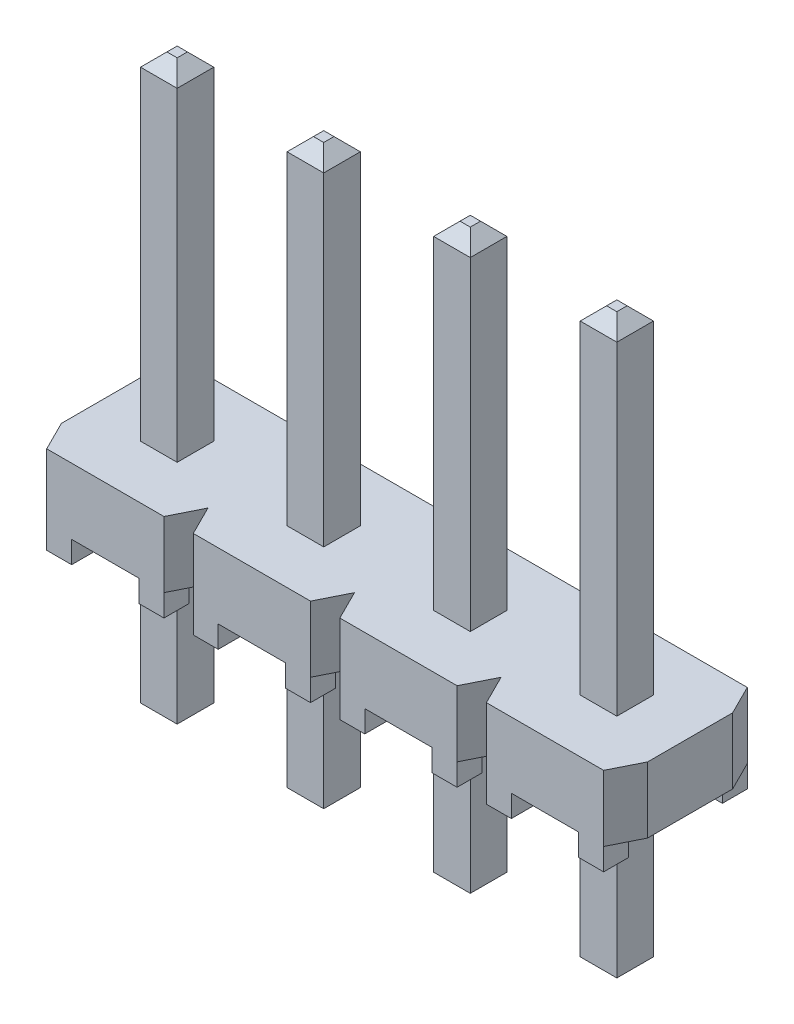
from build123d import *

# Parameters (mm, degrees)
SKETCH1_W                        = 10.16
SKETCH1_H                        = 2.4892
BASE_EXTRUDE_DEPTH               = 0.5715
SNAP_GROOVES_DEPTH               = 2.143
SKETCH4_W                        = 0.4318
SKETCH4_H                        = 0.4318
STANDOFFS_DEPTH                  = 0.381
POSITION_PATTERN_COUNT           = 4
POSITION_PATTERN_PITCH           = 2.54
SKETCH5_W                        = 0.635
SKETCH5_H                        = 10
TERMINAL_TH_DEPTH                = 0.3175
T1_TIP1_SIZE                     = 0.2286
TERMINAL_PATTERN_COUNT           = 4
TERMINAL_PATTERN_PITCH           = 2.54
T1_TIP1_OF_TERMINAL_PATTERN_SIZE = 0.2286


with BuildPart() as part:
    # Sketch1 → Base-Extrude (new body, symmetric)
    with BuildSketch(Plane(origin=(0, 0, 0), x_dir=(1, 0, 0), z_dir=(0, 1, 0))):
        Rectangle(SKETCH1_W, SKETCH1_H)
    extrude(amount=BASE_EXTRUDE_DEPTH, both=True)

    # Sketch3 → Snap Grooves (cut, through all)
    with BuildSketch(Plane(origin=(0, 0.5715, 0), x_dir=(-1, 0, 0), z_dir=(0, 1, 0))):
        Polygon((2.286, 1.2446), (2.794, 1.2446), (2.54, 0.7366), align=None)
        Polygon((2.286, -1.2446), (2.794, -1.2446), (2.54, -0.7366), align=None)
        Polygon((5.08, -0.7366), (5.334, -1.2446), (4.826, -1.2446), align=None)
        Polygon((5.08, 0.7366), (5.334, 1.2446), (4.826, 1.2446), align=None)
    snap_grooves = extrude(amount=-SNAP_GROOVES_DEPTH, mode=Mode.SUBTRACT)

    # Sketch4 → Standoffs (add)
    with BuildSketch(Plane.XZ.offset(0.5715)):
        with Locations((-4.6101, 1.0287)):
            Rectangle(SKETCH4_W, SKETCH4_H)
        with Locations((-3.0099, 1.0287)):
            Rectangle(SKETCH4_W, SKETCH4_H)
        with Locations((-3.0099, -1.0287)):
            Rectangle(SKETCH4_W, SKETCH4_H)
        with Locations((-4.6101, -1.0287)):
            Rectangle(SKETCH4_W, SKETCH4_H)
    standoffs = extrude(amount=STANDOFFS_DEPTH)

    # Position Pattern: Snap Grooves, Standoffs ×4
    with Locations(*[(i * POSITION_PATTERN_PITCH, 0, 0) for i in range(1, POSITION_PATTERN_COUNT)]):
        add(snap_grooves, mode=Mode.SUBTRACT)
        add(standoffs)

    # Sketch5 → Terminal -TH (add, symmetric)
    with BuildSketch(Plane.ZY.offset(3.81)):
        with Locations((0, 1.4135)):
            Rectangle(SKETCH5_W, SKETCH5_H)
    terminal_th = extrude(amount=TERMINAL_TH_DEPTH, both=True)

    # T1 Tip1
    t1_tip1_edges = [part.edges().sort_by_distance(p)[0] for p in [
        (-3.81, -3.5865, 0.3175),
        (-4.1275, -3.5865, 0),
        (-3.81, 6.4135, -0.3175),
        (-3.4925, -3.5865, 0),
        (-3.81, -3.5865, -0.3175),
        (-3.4925, 6.4135, 0),
        (-3.81, 6.4135, 0.3175),
        (-4.1275, 6.4135, 0),
    ]]
    chamfer(t1_tip1_edges, length=T1_TIP1_SIZE)

    # Terminal Pattern: Terminal -TH ×4
    with Locations(*[(i * TERMINAL_PATTERN_PITCH, 0, 0) for i in range(1, TERMINAL_PATTERN_COUNT)]):
        add(terminal_th)

    # T1 Tip1 of Terminal Pattern
    t1_tip1_of_terminal_pattern_edges = [part.edges().sort_by_distance(p)[0] for p in [
        (-1.27, -3.5865, 0.3175),
        (-1.5875, -3.5865, 0),
        (-1.27, 6.4135, -0.3175),
        (-0.9525, -3.5865, 0),
        (-1.27, -3.5865, -0.3175),
        (-0.9525, 6.4135, 0),
        (-1.27, 6.4135, 0.3175),
        (-1.5875, 6.4135, 0),
        (1.27, -3.5865, 0.3175),
        (0.9525, -3.5865, 0),
        (1.27, 6.4135, -0.3175),
        (1.5875, -3.5865, 0),
        (1.27, -3.5865, -0.3175),
        (1.5875, 6.4135, 0),
        (1.27, 6.4135, 0.3175),
        (0.9525, 6.4135, 0),
        (3.81, -3.5865, 0.3175),
        (3.4925, -3.5865, 0),
        (3.81, 6.4135, -0.3175),
        (4.1275, -3.5865, 0),
        (3.81, -3.5865, -0.3175),
        (4.1275, 6.4135, 0),
        (3.81, 6.4135, 0.3175),
        (3.4925, 6.4135, 0),
    ]]
    chamfer(t1_tip1_of_terminal_pattern_edges, length=T1_TIP1_OF_TERMINAL_PATTERN_SIZE)


solid = part.part
